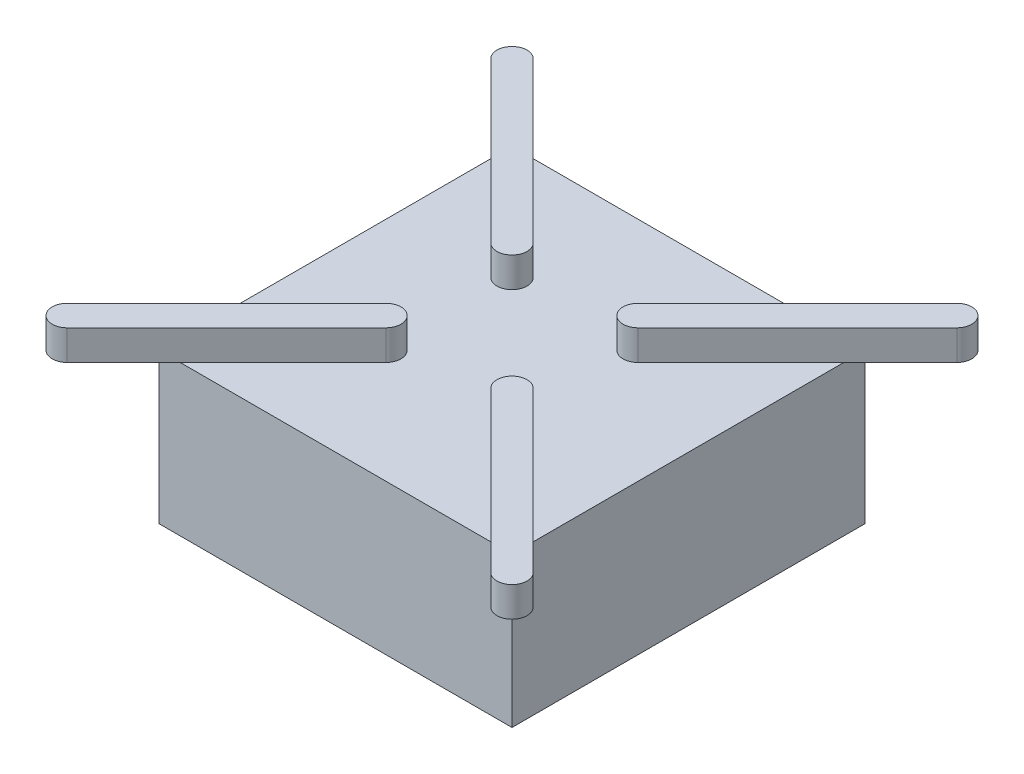
from build123d import *

# Parameters (mm, degrees)
ESQUISSE1_W        = 47
ESQUISSE1_H        = 47
BOSS_EXTRU_1_DEPTH = 20
ESQUISSE2_R        = 1
BOSS_EXTRU_2_DEPTH = 3
BOSS_EXTRU_3_DEPTH = 4
ESQUISSE4_W        = 26
ESQUISSE4_H        = 26
BOSS_EXTRU_4_DEPTH = 2


with BuildPart() as part:
    # Esquisse1 → Boss.-Extru.1 (new body)
    with BuildSketch(Plane(origin=(0, 0, 0), x_dir=(1, 0, 0), z_dir=(0, 1, 0))):
        Rectangle(ESQUISSE1_W, ESQUISSE1_H)
    extrude(amount=BOSS_EXTRU_1_DEPTH)

    # Esquisse2 → Boss.-Extru.2 (add)
    with BuildSketch(Plane.XZ):
        with Locations((19, -19)):
            Circle(ESQUISSE2_R)
        with Locations((-19, -19)):
            Circle(ESQUISSE2_R)
        with Locations((-19, 19)):
            Circle(ESQUISSE2_R)
        with Locations((19, 19)):
            Circle(ESQUISSE2_R)
    extrude(amount=BOSS_EXTRU_2_DEPTH)

    # Esquisse3 → Boss.-Extru.3 (add)
    with BuildSketch(Plane(origin=(0, 20, 0), x_dir=(1, 0, 0), z_dir=(0, 1, 0))):
        with BuildLine():
            Line((9.807611845, -6.97918472), (31.02081528, -28.192388155))
            ThreePointArc((31.02081528, -28.192388155), (31.02081528, -31.02081528), (28.192388155, -31.02081528))
            Line((28.192388155, -31.02081528), (6.97918472, -9.807611845))
            ThreePointArc((6.97918472, -9.807611845), (6.97918472, -6.97918472), (9.807611845, -6.97918472))
        make_face()
        with BuildLine():
            Line((9.807611845, 6.97918472), (31.02081528, 28.192388155))
            ThreePointArc((31.02081528, 28.192388155), (31.02081528, 31.02081528), (28.192388155, 31.02081528))
            Line((28.192388155, 31.02081528), (6.97918472, 9.807611845))
            ThreePointArc((6.97918472, 9.807611845), (6.97918472, 6.97918472), (9.807611845, 6.97918472))
        make_face()
        with BuildLine():
            Line((-9.807611845, -6.97918472), (-31.02081528, -28.192388155))
            ThreePointArc((-31.02081528, -28.192388155), (-31.02081528, -31.02081528), (-28.192388155, -31.02081528))
            Line((-28.192388155, -31.02081528), (-6.97918472, -9.807611845))
            ThreePointArc((-6.97918472, -9.807611845), (-6.97918472, -6.97918472), (-9.807611845, -6.97918472))
        make_face()
        with BuildLine():
            Line((-9.807611845, 6.97918472), (-31.02081528, 28.192388155))
            ThreePointArc((-31.02081528, 28.192388155), (-31.02081528, 31.02081528), (-28.192388155, 31.02081528))
            Line((-28.192388155, 31.02081528), (-6.97918472, 9.807611845))
            ThreePointArc((-6.97918472, 9.807611845), (-6.97918472, 6.97918472), (-9.807611845, 6.97918472))
        make_face()
    extrude(amount=BOSS_EXTRU_3_DEPTH)

    # Esquisse4 → Boss.-Extru.4 (add)
    with BuildSketch(Plane.XZ):
        Rectangle(ESQUISSE4_W, ESQUISSE4_H)
    extrude(amount=BOSS_EXTRU_4_DEPTH)


solid = part.part
